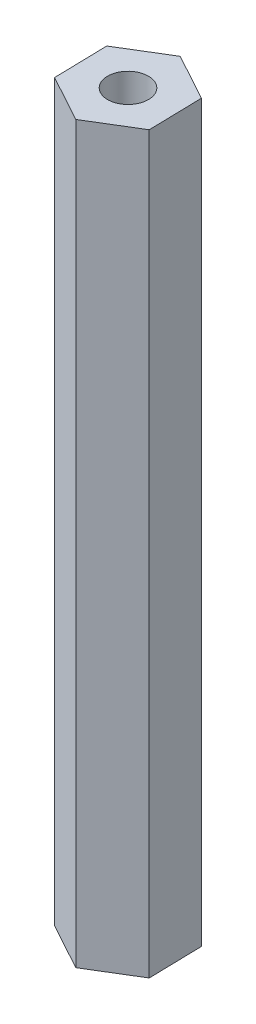
from build123d import *

# Parameters (mm, degrees)
BOSS_EXTRUDE1_DEPTH         = 50.8
F_34_0_111_DIAMETER_HOLE1_D = 2.8194


with BuildPart() as part:
    # Sketch1 → Boss-Extrude1 (new body)
    with BuildSketch(Plane(origin=(0, 0, 0), x_dir=(1, 0, 0), z_dir=(0, 1, 0))):
        Polygon((3.15669384, 1.921465816), (-0.085691289, 3.694509965), (-3.242385129, 1.77304415), (-3.15669384, -1.921465816), (0.085691289, -3.694509965), (3.242385129, -1.77304415), align=None)
    extrude(amount=BOSS_EXTRUDE1_DEPTH)

    # #34 (0.111) Diameter Hole1 (through all)
    with Locations(Plane(origin=(0, 0, 0), x_dir=(-1, 0, 0), z_dir=(0, -1, 0))):
        with Locations((0, 0)):
            Hole(F_34_0_111_DIAMETER_HOLE1_D / 2)


solid = part.part
